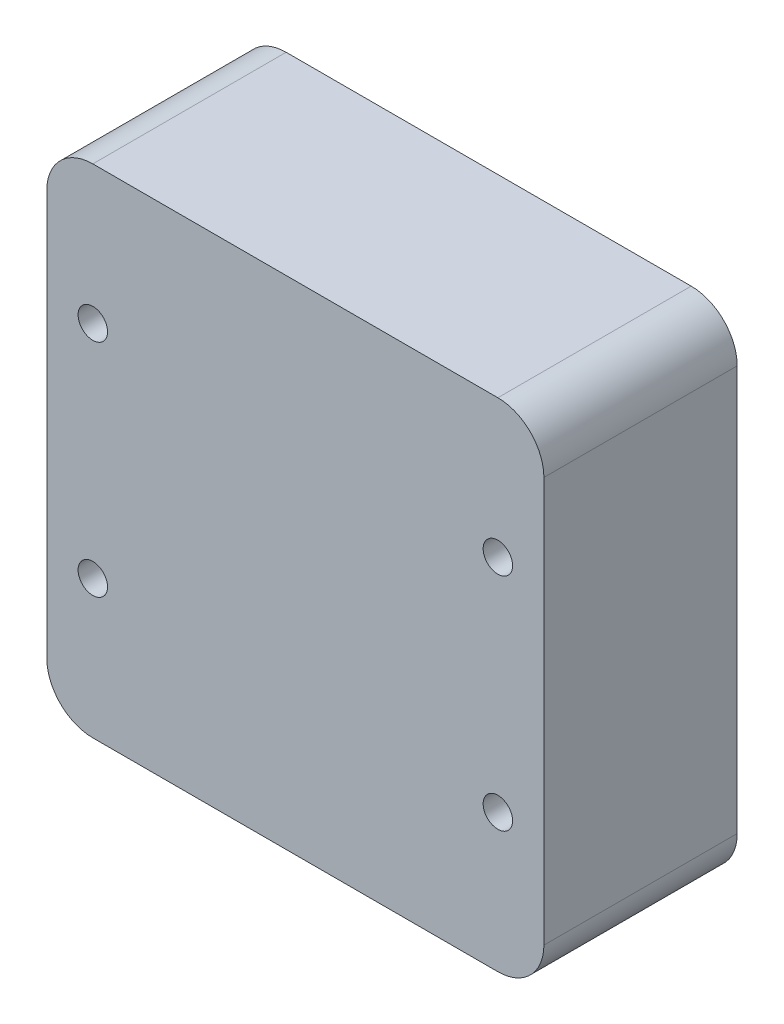
from build123d import *

# Parameters (mm, degrees)
SKETCH_1_W          = 54
SKETCH_1_H          = 54
EXTRUDE_1_DEPTH     = 21
FILLET_1_R          = 5
SKETCH_2_R          = 1.6
CUT_EXTRUDE_1_DEPTH = 10


with BuildPart() as part:
    # 草图1 → 凸台-拉伸1 (new body)
    with BuildSketch(Plane.XY):
        with Locations((2.582608696, -10.956521739)):
            Rectangle(SKETCH_1_W, SKETCH_1_H)
    extrude(amount=EXTRUDE_1_DEPTH)

    # 圆角1
    fillet_1_edges = [part.edges().sort_by_distance(p)[0] for p in [
        (-24.417391304, 16.043478261, 10.5),
        (29.582608696, 16.043478261, 10.5),
        (29.582608696, -37.956521739, 10.5),
        (-24.417391304, -37.956521739, 10.5),
    ]]
    fillet(fillet_1_edges, radius=FILLET_1_R)

    # 草图2 → 切除-拉伸1 (cut)
    with BuildSketch(Plane.XY.offset(21)):
        with Locations((24.582608696, -22.956521739)):
            Circle(SKETCH_2_R)
        with Locations((-19.417391304, -22.956521739)):
            Circle(SKETCH_2_R)
        with Locations((-19.417391304, 1.043478261)):
            Circle(SKETCH_2_R)
        with Locations((24.582608696, 1.043478261)):
            Circle(SKETCH_2_R)
    extrude(amount=-CUT_EXTRUDE_1_DEPTH, mode=Mode.SUBTRACT)


solid = part.part
